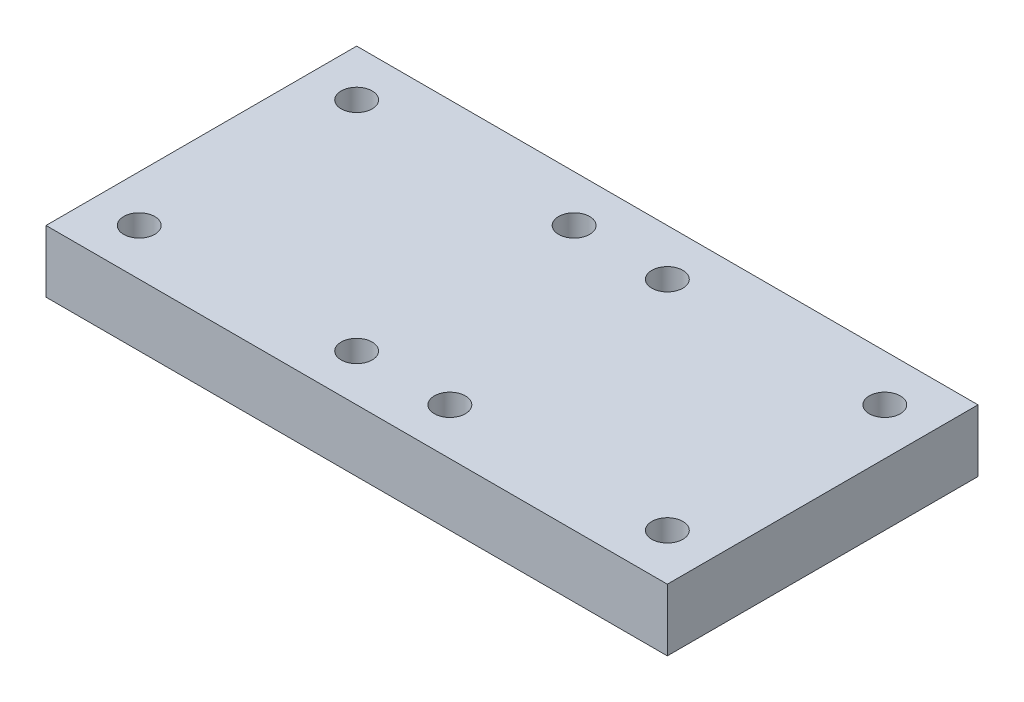
from build123d import *

# Parameters (mm, degrees)
SKETCH1_W           = 100
SKETCH1_H           = 50
SKETCH1_R           = 2.5
BOSS_EXTRUDE1_DEPTH = 10
SKETCH3_R           = 2.5
CUT_EXTRUDE1_DEPTH  = 10


with BuildPart() as part:
    # Sketch1 → Boss-Extrude1 (new body)
    with BuildSketch(Plane(origin=(0, 0, 0), x_dir=(1, 0, 0), z_dir=(0, 1, 0))):
        Rectangle(SKETCH1_W, SKETCH1_H)
        with Locations((-42.5, 17.5)):
            Circle(SKETCH1_R, mode=Mode.SUBTRACT)
        with Locations((42.5, 17.5)):
            Circle(SKETCH1_R, mode=Mode.SUBTRACT)
        with Locations((42.5, -17.5)):
            Circle(SKETCH1_R, mode=Mode.SUBTRACT)
        with Locations((-42.5, -17.5)):
            Circle(SKETCH1_R, mode=Mode.SUBTRACT)
    extrude(amount=BOSS_EXTRUDE1_DEPTH)

    # Sketch3 → Cut-Extrude1 (cut)
    with BuildSketch(Plane(origin=(0, 10, 0), x_dir=(1, 0, 0), z_dir=(0, 1, 0))):
        with Locations((-7.5, 17.5)):
            Circle(SKETCH3_R)
        with Locations((7.5, 17.5)):
            Circle(SKETCH3_R)
        with Locations((7.5, -17.5)):
            Circle(SKETCH3_R)
        with Locations((-7.5, -17.5)):
            Circle(SKETCH3_R)
    extrude(amount=-CUT_EXTRUDE1_DEPTH, mode=Mode.SUBTRACT)


solid = part.part
